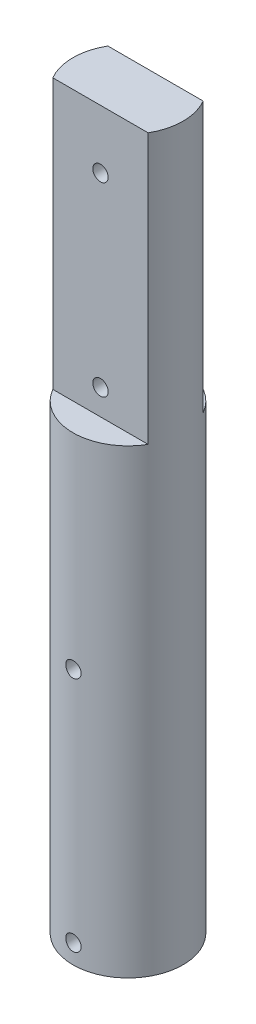
from build123d import *

# Parameters (mm, degrees)
SKETCH2_R               = 4.3
BOSS_EXTRUDE2_DEPTH     = 57.08
CUT_EXTRUDE2_DEPTH      = 21.08
SKETCH6_R               = 0.6
CUT_EXTRUDE3_DEPTH      = 5.3
CUT_EXTRUDE3_DEPTH_BACK = 5.3
SKETCH7_R               = 0.6
CUT_EXTRUDE4_DEPTH      = 10
SKETCH8_R               = 0.6
CUT_EXTRUDE5_DEPTH      = 5.3000001
CUT_EXTRUDE5_DEPTH_BACK = 5.3000001
SKETCH9_R               = 0.6
CUT_EXTRUDE6_DEPTH      = 7.4500001


with BuildPart() as part:
    # Sketch2 → Boss-Extrude2 (new body)
    with BuildSketch(Plane(origin=(0, 0, 0), x_dir=(1, 0, 0), z_dir=(0, 1, 0))):
        Circle(SKETCH2_R)
    extrude(amount=BOSS_EXTRUDE2_DEPTH)

    # Sketch4 → Cut-Extrude2 (cut)
    with BuildSketch(Plane(origin=(0, 57.08, 0), x_dir=(1, 0, 0), z_dir=(0, 1, 0))):
        with BuildLine():
            Line((0, 2.15), (-3.723909236, 2.15))
            ThreePointArc((-3.723909236, 2.15), (0, 4.3), (3.723909236, 2.15))
            Line((3.723909236, 2.15), (0, 2.15))
        make_face()
        with BuildLine():
            Line((0, -2.15), (-3.723909236, -2.15))
            ThreePointArc((-3.723909236, -2.15), (0, -4.3), (3.723909236, -2.15))
            Line((3.723909236, -2.15), (0, -2.15))
        make_face()
    extrude(amount=-CUT_EXTRUDE2_DEPTH, mode=Mode.SUBTRACT)

    # Sketch6 → Cut-Extrude3 (cut, two sides)
    with BuildSketch(Plane.XY) as cut_extrude3_sk:
        with Locations((0, 1.5)):
            Circle(SKETCH6_R)
    extrude(amount=CUT_EXTRUDE3_DEPTH, mode=Mode.SUBTRACT)
    extrude(cut_extrude3_sk.sketch, amount=-CUT_EXTRUDE3_DEPTH_BACK, mode=Mode.SUBTRACT)

    # Sketch7 → Cut-Extrude4 (cut)
    with BuildSketch(Plane.XY.offset(2.15)):
        with Locations((0, 38)):
            Circle(SKETCH7_R)
    extrude(amount=-CUT_EXTRUDE4_DEPTH, mode=Mode.SUBTRACT)

    # Sketch8 → Cut-Extrude5 (cut, two sides)
    with BuildSketch(Plane.XY) as cut_extrude5_sk:
        with Locations((0, 20)):
            Circle(SKETCH8_R)
    extrude(amount=CUT_EXTRUDE5_DEPTH, mode=Mode.SUBTRACT)
    extrude(cut_extrude5_sk.sketch, amount=-CUT_EXTRUDE5_DEPTH_BACK, mode=Mode.SUBTRACT)

    # Sketch9 → Cut-Extrude6 (cut, through all)
    with BuildSketch(Plane.XY.offset(2.15)):
        with Locations((0, 52.5)):
            Circle(SKETCH9_R)
    extrude(amount=-CUT_EXTRUDE6_DEPTH, mode=Mode.SUBTRACT)


solid = part.part
